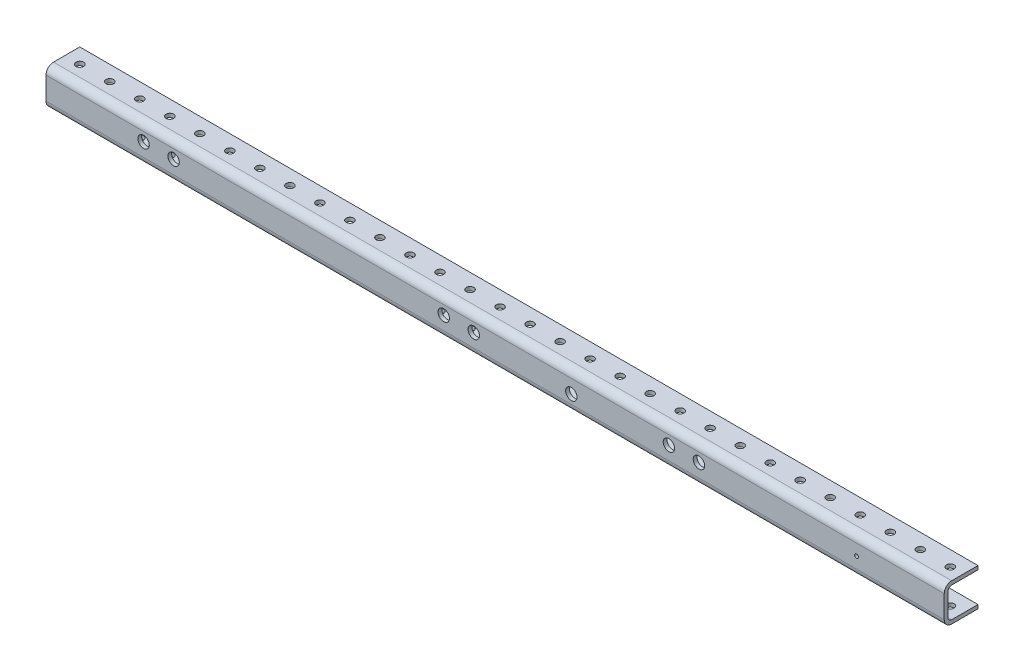
from build123d import *

# Parameters (mm, degrees)
SKETCH1_W          = 889
SKETCH1_H          = 31.75
EXTRUDE1_DEPTH     = 28.575
EXTRUDE2_REACH     = 891.702
SKETCH2_W          = 25.4
SKETCH2_H          = 25.4
HOLE1_D            = 6.35
HOLE1_DEPTH        = 3.175
LPATTERN1_COUNT    = 35
LPATTERN1_PITCH    = 25.4
HOLE2_D            = 9.652
LPATTERN2_COUNT    = 12
LPATTERN2_PITCH    = 25.4
HOLE3_D            = 9.652
HOLE4_D            = 9.652
LPATTERN3_COUNT    = 12
LPATTERN3_PITCH    = 25.4
HOLE5_D            = 3.175
HOLE6_D            = 6.35
LPATTERN4_COUNT    = 35
LPATTERN4_PITCH    = 25.4
FILLET1_R          = 3.175
FILLET2_R          = 3.175
FILLET3_R          = 6.35
FILLET4_R          = 6.35
SKETCH15_W         = 132.395488749
SKETCH15_H         = 60.665431042
CUT_EXTRUDE1_DEPTH = 874.926383539


with BuildPart() as part:
    # Sketch1 → Extrude1 (new body)
    with BuildSketch(Plane.XY.offset(3.175)):
        with Locations((428.480011997, 8.672957166)):
            Rectangle(SKETCH1_W, SKETCH1_H)
    extrude(amount=-EXTRUDE1_DEPTH)

    # Sketch2 → Extrude2 (cut, up to next)
    with BuildSketch(Plane.ZY.offset(16.019988003), mode=Mode.PRIVATE) as extrude2_sk1:
        with Locations((-12.7, 8.672957166)):
            Rectangle(SKETCH2_W, SKETCH2_H)
    extrude2_tool1 = extrude(extrude2_sk1.sketch, amount=-EXTRUDE2_REACH, mode=Mode.PRIVATE) & part.part
    add(extrude2_tool1.solids().sort_by_distance((-16.019988, 8.672957, -12.7))[0], mode=Mode.SUBTRACT)

    # Hole1
    with Locations(Plane(origin=(0, 24.547957166, 0), x_dir=(-1, 0, 0), z_dir=(0, 1, 0))):
        with Locations((3.319988003, -12.7)):
            hole1 = Hole(HOLE1_D / 2, depth=HOLE1_DEPTH)

    # LPattern1: Hole1 ×35
    with Locations(*[(i * LPATTERN1_PITCH, 0, 0) for i in range(1, LPATTERN1_COUNT)]):
        add(hole1, mode=Mode.SUBTRACT)

    # Hole2 (through all)
    with Locations(Plane.XY.offset(3.175)):
        with Locations((66.530011997, 10.577957166)):
            hole2 = Hole(HOLE2_D / 2)

    # LPattern2: Hole2 ×12, 8 skipped
    with Locations(*[(i * LPATTERN2_PITCH, 0, 0) for i in range(1, LPATTERN2_COUNT) if i not in (2, 3, 4, 5, 6, 7, 8, 9)]):
        add(hole2, mode=Mode.SUBTRACT)

    # Hole3 (through all)
    with Locations(Plane.XY.offset(3.175)):
        with Locations((428.480011997, 6.767957166)):
            Hole(HOLE3_D / 2)

    # Hole4 (through all)
    with Locations(Plane.XY.offset(3.175)):
        with Locations((511.030011997, 10.577957166)):
            hole4 = Hole(HOLE4_D / 2)

    # LPattern3: Hole4 ×12, 8 skipped
    with Locations(*[(i * LPATTERN3_PITCH, 0, 0) for i in range(1, LPATTERN3_COUNT) if i not in (2, 3, 4, 5, 6, 7, 8, 9)]):
        add(hole4, mode=Mode.SUBTRACT)

    # Hole5 (through all)
    with Locations(Plane.XY.offset(3.175)):
        with Locations((669.780011997, 8.672957166)):
            Hole(HOLE5_D / 2)

    # Hole6 (through all)
    with Locations(Plane(origin=(0, -4.027042834, 0), x_dir=(-1, 0, 0), z_dir=(0, 1, 0))):
        with Locations((3.319988003, -12.7)):
            hole6 = Hole(HOLE6_D / 2)

    # LPattern4: Hole6 ×35
    with Locations(*[(i * LPATTERN4_PITCH, 0, 0) for i in range(1, LPATTERN4_COUNT)]):
        add(hole6, mode=Mode.SUBTRACT)

    # Fillet1
    fillet1_edges = [part.edges().sort_by_distance(p)[0] for p in [
        (428.480011997, 21.372957166, 0),
    ]]
    fillet(fillet1_edges, radius=FILLET1_R)

    # Fillet2
    fillet2_edges = [part.edges().sort_by_distance(p)[0] for p in [
        (428.480011997, -4.027042834, 0),
    ]]
    fillet(fillet2_edges, radius=FILLET2_R)

    # Fillet3
    fillet3_edges = [part.edges().sort_by_distance(p)[0] for p in [
        (428.480011997, -7.202042834, 3.175),
    ]]
    fillet(fillet3_edges, radius=FILLET3_R)

    # Fillet4
    fillet4_edges = [part.edges().sort_by_distance(p)[0] for p in [
        (428.480011997, 24.547957166, 3.175),
    ]]
    fillet(fillet4_edges, radius=FILLET4_R)

    # Sketch15 → Cut-Extrude1 (cut, through all)
    with BuildSketch(Plane(origin=(0, 24.547957166, 0), x_dir=(1, 0, 0), z_dir=(0, 1, 0))):
        with Locations((810.177756371, 19.634805261)):
            Rectangle(SKETCH15_W, SKETCH15_H)
    extrude(amount=-CUT_EXTRUDE1_DEPTH, mode=Mode.SUBTRACT)


solid = part.part
